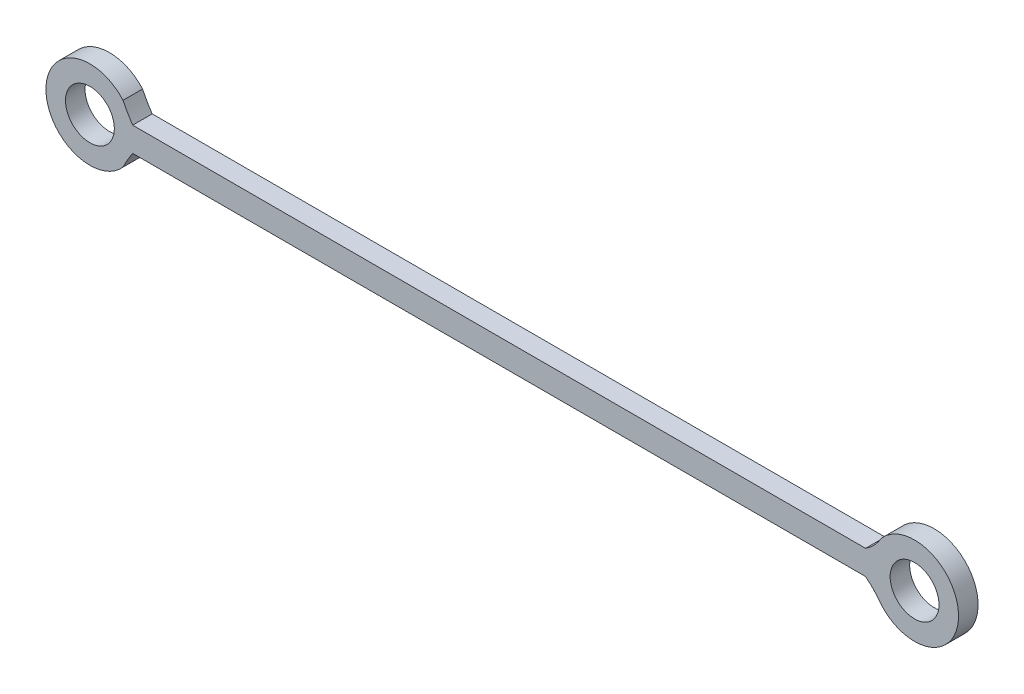
from build123d import *

# Parameters (mm, degrees)
SKETCH_1_R      = 5
EXTRUDE_1_DEPTH = 4


with BuildPart() as part:
    # 草图1 → 凸台-拉伸1 (new body)
    with BuildSketch(Plane.XY):
        with BuildLine():
            Line((-67.497283214, -2.5), (82.476937878, -2.5))
            ThreePointArc((82.476937878, -2.5), (84.223410122, -4.092965878), (85.722010937, -5.921052632))
            ThreePointArc((85.722010937, -5.921052632), (101.5, 0), (85.722010937, 5.921052632))
            ThreePointArc((85.722010937, 5.921052632), (84.303998499, 4.016522981), (82.476937878, 2.5))
            Line((82.476937878, 2.5), (-67.497283214, 2.5))
            ThreePointArc((-67.497283214, 2.5), (-68.543334858, 4.176650079), (-69.472010937, 5.921052632))
            ThreePointArc((-69.472010937, 5.921052632), (-85.25, 0), (-69.472010937, -5.921052632))
            ThreePointArc((-69.472010937, -5.921052632), (-68.543334858, -4.176650079), (-67.497283214, -2.5))
        make_face()
        with Locations((92.5, 0)):
            Circle(SKETCH_1_R, mode=Mode.SUBTRACT)
        with Locations((-76.25, 0)):
            Circle(SKETCH_1_R, mode=Mode.SUBTRACT)
    extrude(amount=EXTRUDE_1_DEPTH)


solid = part.part
